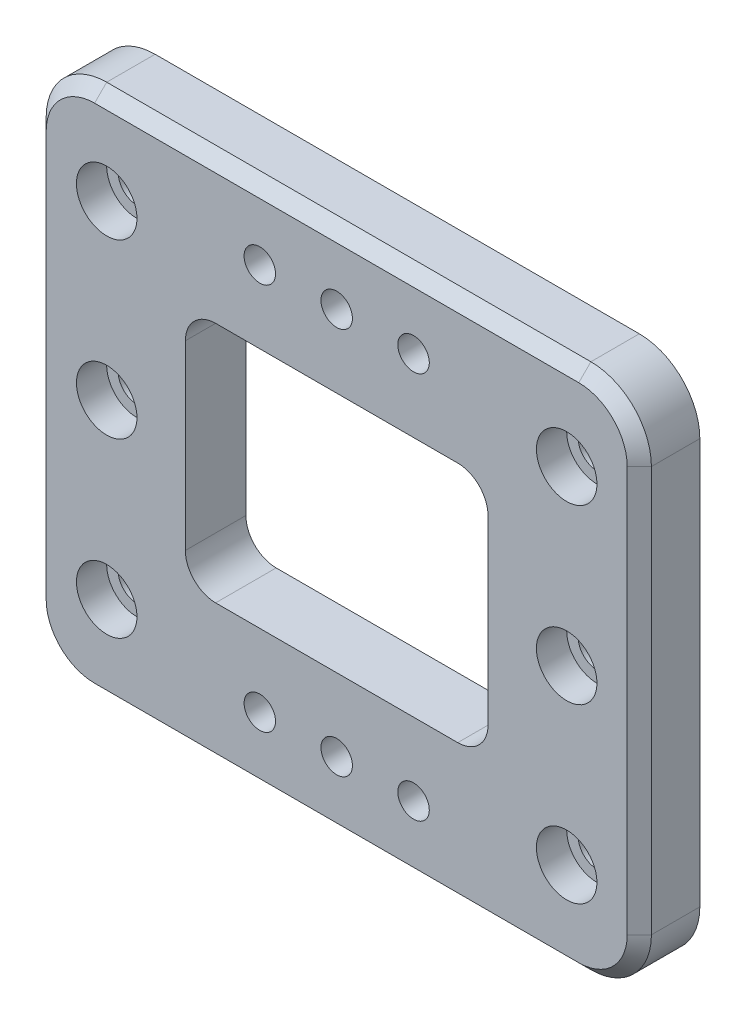
from build123d import *

# Parameters (mm, degrees)
SKETCH_1_W          = 100
SKETCH_1_H          = 87
EXTRUDE_1_DEPTH     = 10
FILLET_1_R          = 10
SKETCH_2_R          = 2.6
CUT_EXTRUDE_1_DEPTH = 10
SKETCH_3_R          = 5
CUT_EXTRUDE_2_DEPTH = 5
SKETCH_4_R          = 3.1
CUT_EXTRUDE_3_DEPTH = 5
CHAMFER_1_SIZE      = 1
CHAMFER_2_SIZE      = 2
SKETCH1_W           = 50
SKETCH1_H           = 40
CUT_EXTRUDE1_DEPTH  = 10
FILLET1_R           = 5


with BuildPart() as part:
    # 草图1 → 凸台-拉伸1 (new body)
    with BuildSketch(Plane.XY):
        Rectangle(SKETCH_1_W, SKETCH_1_H)
    extrude(amount=EXTRUDE_1_DEPTH)

    # 圆角1
    fillet_1_edges = [part.edges().sort_by_distance(p)[0] for p in [
        (50, -43.5, 5),
        (-50, -43.5, 5),
        (-50, 43.5, 5),
        (50, 43.5, 5),
    ]]
    fillet(fillet_1_edges, radius=FILLET_1_R)

    # 草图2 → 切除-拉伸1 (cut)
    with BuildSketch(Plane.XY.offset(10)):
        with Locations((0, 32)):
            Circle(SKETCH_2_R)
        with Locations((-12.7, 32)):
            Circle(SKETCH_2_R)
        with Locations((12.7, 32)):
            Circle(SKETCH_2_R)
        with Locations((-12.7, -32)):
            Circle(SKETCH_2_R)
        with Locations((0, -32)):
            Circle(SKETCH_2_R)
        with Locations((12.7, -32)):
            Circle(SKETCH_2_R)
    extrude(amount=-CUT_EXTRUDE_1_DEPTH, mode=Mode.SUBTRACT)

    # 草图3 → 切除-拉伸2 (cut)
    with BuildSketch(Plane.XY.offset(10)):
        with Locations((-38, 28.5)):
            Circle(SKETCH_3_R)
        with Locations((-38, 0)):
            Circle(SKETCH_3_R)
        with Locations((-38, -28.5)):
            Circle(SKETCH_3_R)
        with Locations((38, -28.5)):
            Circle(SKETCH_3_R)
        with Locations((38, 0)):
            Circle(SKETCH_3_R)
        with Locations((38, 28.5)):
            Circle(SKETCH_3_R)
    extrude(amount=-CUT_EXTRUDE_2_DEPTH, mode=Mode.SUBTRACT)

    # 草图4 → 切除-拉伸3 (cut)
    with BuildSketch(Plane.XY.offset(5)):
        with Locations((-38, 28.5)):
            Circle(SKETCH_4_R)
        with Locations((-38, 0)):
            Circle(SKETCH_4_R)
        with Locations((-38, -28.5)):
            Circle(SKETCH_4_R)
        with Locations((38, 28.5)):
            Circle(SKETCH_4_R)
        with Locations((38, 0)):
            Circle(SKETCH_4_R)
        with Locations((38, -28.5)):
            Circle(SKETCH_4_R)
    extrude(amount=-CUT_EXTRUDE_3_DEPTH, mode=Mode.SUBTRACT)

    # 倒角1
    chamfer_1_edges = [part.edges().sort_by_distance(p)[0] for p in [
        (34.9, 0, 0),
        (34.9, -28.5, 0),
        (-41.1, 28.5, 0),
        (-41.1, 0, 0),
        (-41.1, -28.5, 0),
        (34.9, 28.5, 0),
    ]]
    chamfer(chamfer_1_edges, length=CHAMFER_1_SIZE)

    # 倒角2
    chamfer_2_edges = [part.edges().sort_by_distance(p)[0] for p in [
        (0, 43.5, 10),
        (50, 0, 10),
        (-50, 0, 10),
        (0, -43.5, 10),
        (-47.071067812, -40.571067812, 10),
        (47.071067812, -40.571067812, 10),
        (-47.071067812, 40.571067812, 10),
        (47.071067812, 40.571067812, 10),
    ]]
    chamfer(chamfer_2_edges, length=CHAMFER_2_SIZE)

    # Sketch1 → Cut-Extrude1 (cut)
    with BuildSketch(Plane.XY.offset(10)):
        Rectangle(SKETCH1_W, SKETCH1_H)
    extrude(amount=-CUT_EXTRUDE1_DEPTH, mode=Mode.SUBTRACT)

    # Fillet1
    fillet1_edges = [part.edges().sort_by_distance(p)[0] for p in [
        (25, 20, 5),
        (25, -20, 5),
        (-25, -20, 5),
        (-25, 20, 5),
    ]]
    fillet(fillet1_edges, radius=FILLET1_R)


solid = part.part
